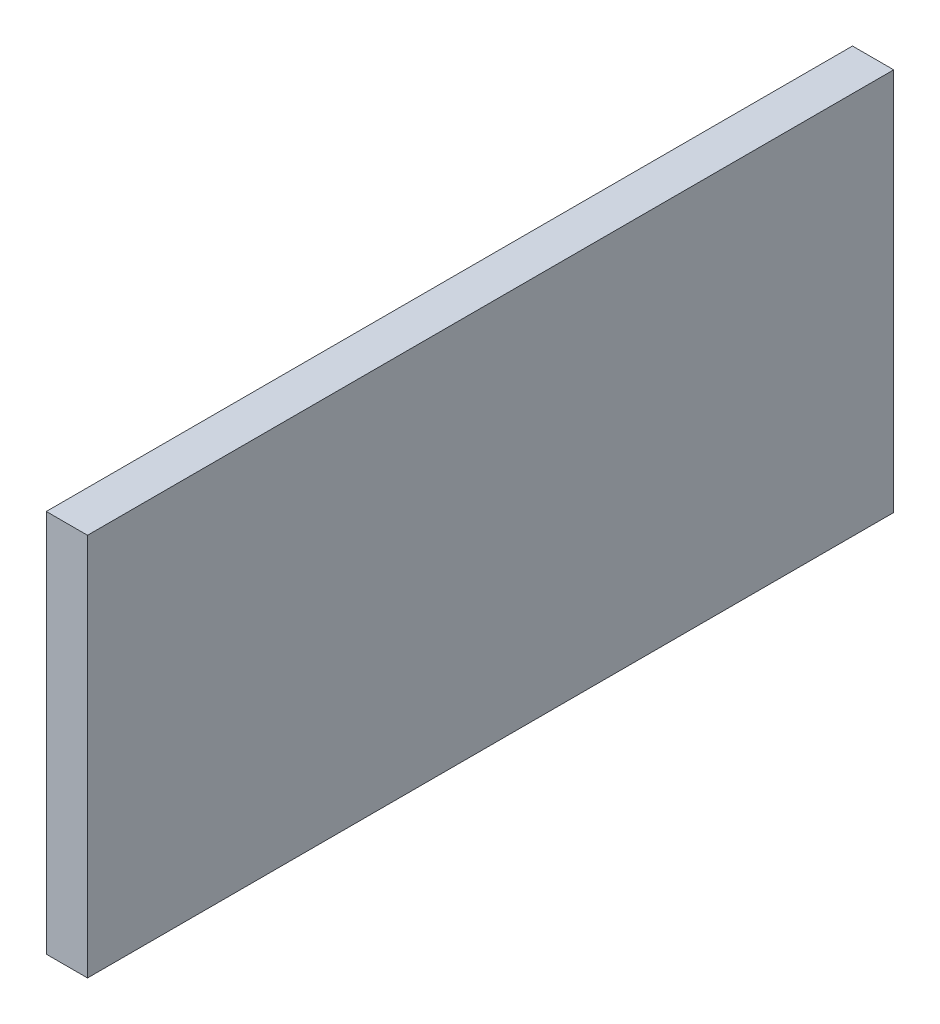
from build123d import *

# Parameters (mm, degrees)
SKETCH1_W           = 3.175
SKETCH1_H           = 29.52
BOSS_EXTRUDE1_DEPTH = 62.07


with BuildPart() as part:
    # Sketch1 → Boss-Extrude1 (new body)
    with BuildSketch(Plane.XY):
        Rectangle(SKETCH1_W, SKETCH1_H)
    extrude(amount=BOSS_EXTRUDE1_DEPTH)


solid = part.part
